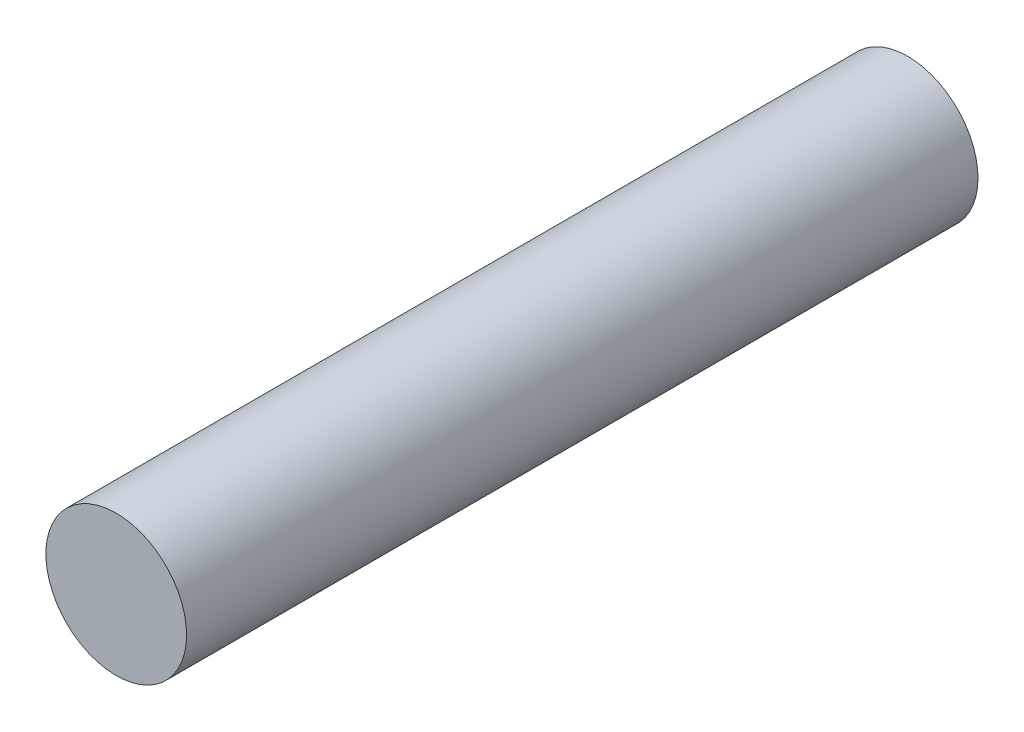
from build123d import *

# Parameters (mm, degrees)
SKETCH_1_R      = 4
EXTRUDE_1_DEPTH = 45


with BuildPart() as part:
    # 草图1 → 凸台-拉伸1 (new body)
    with BuildSketch(Plane.XY):
        Circle(SKETCH_1_R)
    extrude(amount=EXTRUDE_1_DEPTH)


solid = part.part
